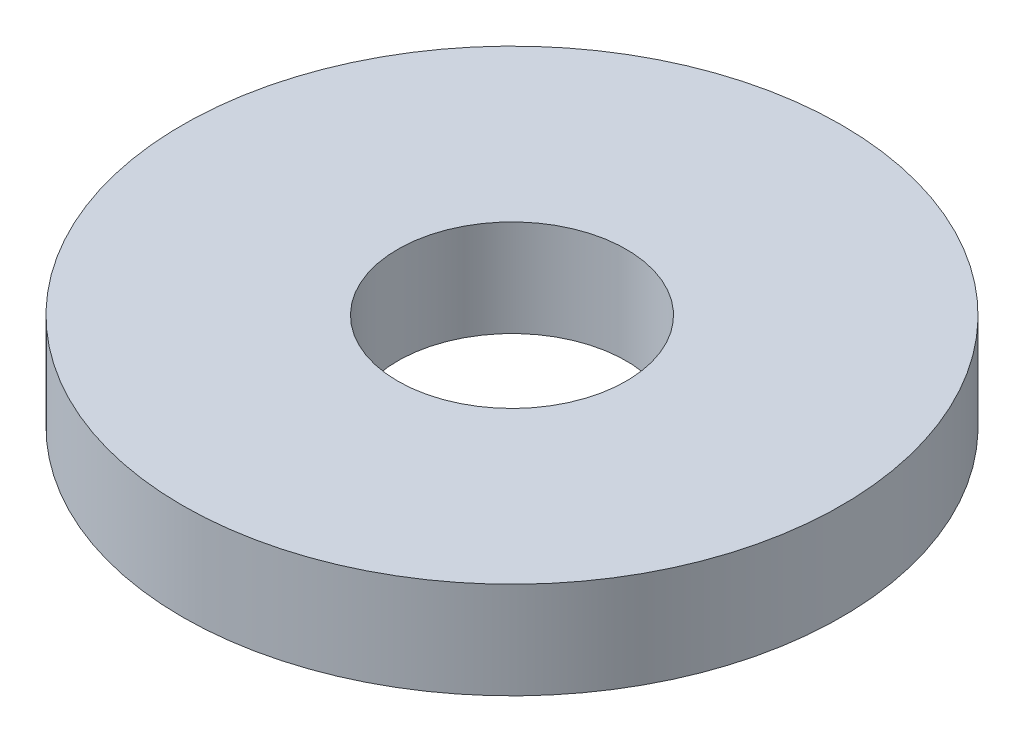
from build123d import *

# Parameters (mm, degrees)
SKETCH1_R           = 3.75
BOSS_EXTRUDE1_DEPTH = 1.1
SKETCH2_R           = 1.3
CUT_EXTRUDE1_DEPTH  = 2.1


with BuildPart() as part:
    # Sketch1 → Boss-Extrude1 (new body)
    with BuildSketch(Plane(origin=(0, 0, 0), x_dir=(1, 0, 0), z_dir=(0, 1, 0))):
        Circle(SKETCH1_R)
    extrude(amount=BOSS_EXTRUDE1_DEPTH)

    # Sketch2 → Cut-Extrude1 (cut, through all)
    with BuildSketch(Plane(origin=(0, 1.1, 0), x_dir=(1, 0, 0), z_dir=(0, 1, 0))):
        Circle(SKETCH2_R)
    extrude(amount=-CUT_EXTRUDE1_DEPTH, mode=Mode.SUBTRACT)


solid = part.part
